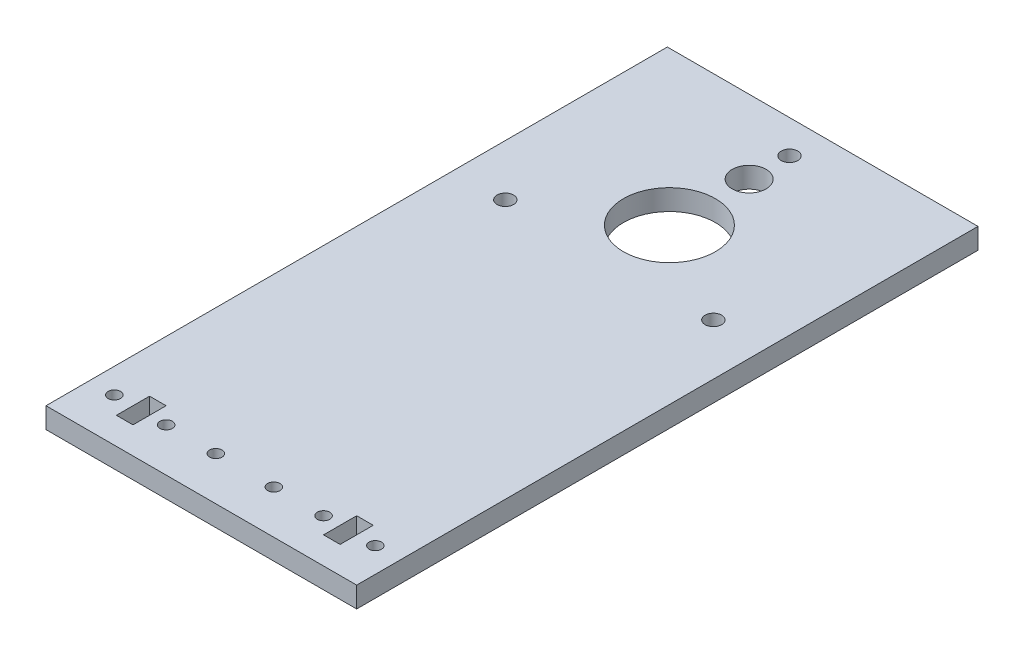
from build123d import *

# Parameters (mm, degrees)
SKETCH_1_R          = 1.5
SKETCH_1_W          = 4
SKETCH_1_H          = 8
SKETCH_1_R_2        = 4.1
SKETCH_1_R_3        = 11.1
EXTRUDE_6_DEPTH     = 5
SKETCH_2_R          = 2
CUT_EXTRUDE_1_DEPTH = 10


with BuildPart() as part:
    # 草图1 → 凸台-拉伸6 (new body)
    with BuildSketch(Plane(origin=(0, 0, 0), x_dir=(1, 0, 0), z_dir=(0, 1, 0))):
        Polygon((75, 150), (37.5, 150), (0, 150), (0, 0), (75, 0), align=None)
        with Locations((6, 10.5)):
            Circle(SKETCH_1_R, mode=Mode.SUBTRACT)
        with Locations((12.5, 10.5)):
            Rectangle(SKETCH_1_W, SKETCH_1_H, mode=Mode.SUBTRACT)
        with Locations((18.5, 10.5)):
            Circle(SKETCH_1_R, mode=Mode.SUBTRACT)
        with Locations((30.5, 10.5)):
            Circle(SKETCH_1_R, mode=Mode.SUBTRACT)
        with Locations((44.5, 10.5)):
            Circle(SKETCH_1_R, mode=Mode.SUBTRACT)
        with Locations((56.5, 10.5)):
            Circle(SKETCH_1_R, mode=Mode.SUBTRACT)
        with Locations((62.5, 10.5)):
            Rectangle(SKETCH_1_W, SKETCH_1_H, mode=Mode.SUBTRACT)
        with Locations((69, 10.5)):
            Circle(SKETCH_1_R, mode=Mode.SUBTRACT)
        with Locations((37.5, 132.25)):
            Circle(SKETCH_1_R_2, mode=Mode.SUBTRACT)
        with Locations((37.5, 113)):
            Circle(SKETCH_1_R_3, mode=Mode.SUBTRACT)
    extrude(amount=EXTRUDE_6_DEPTH)

    # 草图2 → 切除-拉伸1 (cut)
    with BuildSketch(Plane(origin=(0, 5, 0), x_dir=(1, 0, 0), z_dir=(0, 1, 0))):
        with Locations((37.5, 142)):
            Circle(SKETCH_2_R)
        with Locations((62.61473671, 98.5)):
            Circle(SKETCH_2_R)
        with Locations((12.38526329, 98.5)):
            Circle(SKETCH_2_R)
    extrude(amount=-CUT_EXTRUDE_1_DEPTH, mode=Mode.SUBTRACT)


solid = part.part
